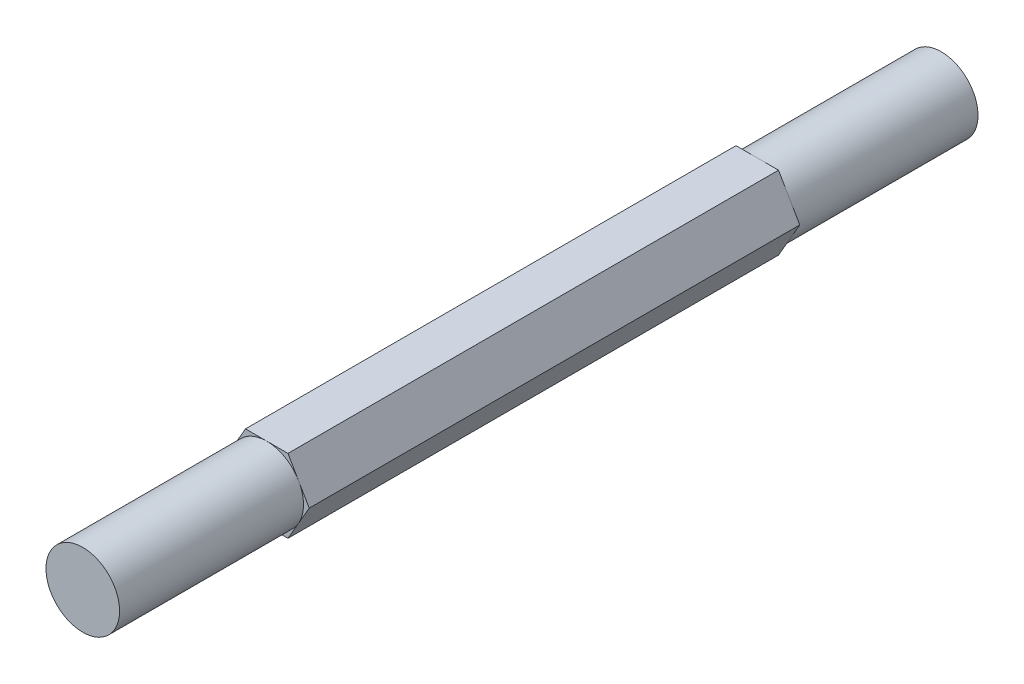
from build123d import *

# Parameters (mm, degrees)
BOSS_EXTRUDE1_DEPTH = 80
SKETCH2_R           = 6
BOSS_EXTRUDE2_DEPTH = 30
SKETCH3_R           = 6
BOSS_EXTRUDE3_DEPTH = 30


with BuildPart() as part:
    # Sketch1 → Boss-Extrude1 (new body)
    with BuildSketch(Plane.XY):
        Polygon((3.464101615, 6), (-3.464101615, 6), (-6.92820323, 0), (-3.464101615, -6), (3.464101615, -6), (6.92820323, 0), align=None)
    extrude(amount=BOSS_EXTRUDE1_DEPTH)

    # Sketch2 → Boss-Extrude2 (add)
    with BuildSketch(Plane.XY.offset(80)):
        Circle(SKETCH2_R)
    extrude(amount=BOSS_EXTRUDE2_DEPTH)

    # Sketch3 → Boss-Extrude3 (add)
    with BuildSketch(Plane(origin=(0, 0, 0), x_dir=(-1, 0, 0), z_dir=(0, 0, -1))):
        Circle(SKETCH3_R)
    extrude(amount=BOSS_EXTRUDE3_DEPTH)


solid = part.part
